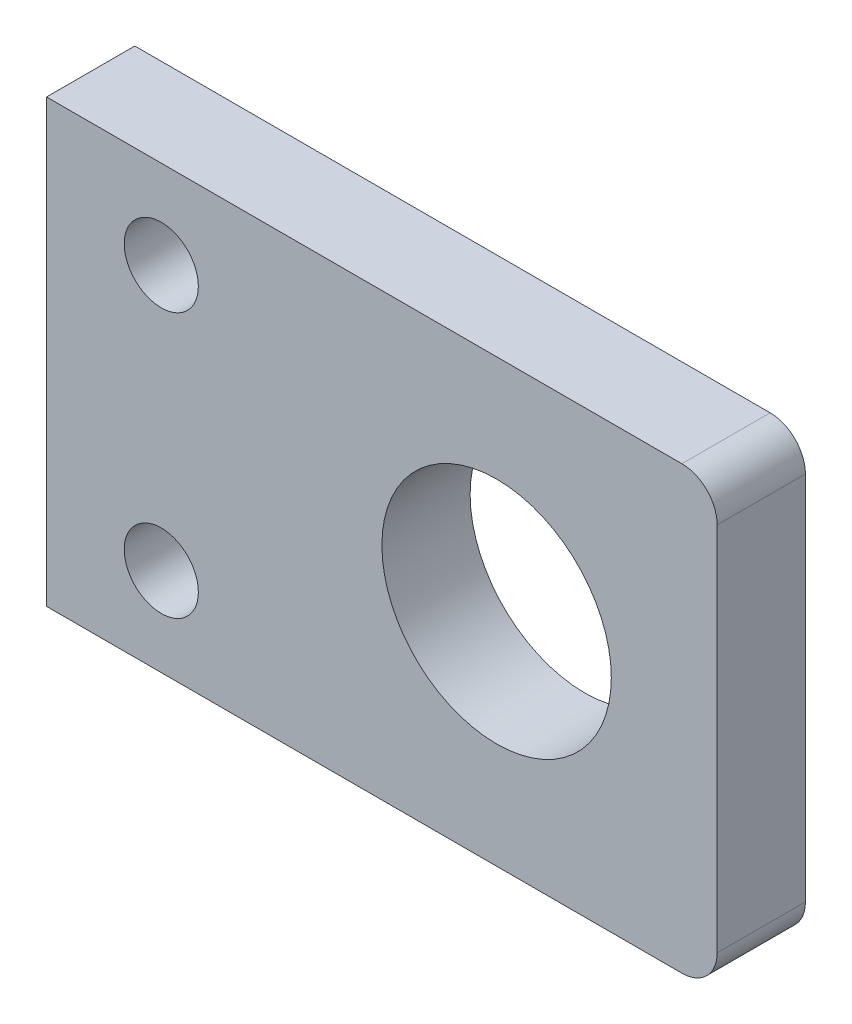
from build123d import *

# Parameters (mm, degrees)
SKETCH_1_R      = 2.1
SKETCH_1_R_2    = 6.5
EXTRUDE_1_DEPTH = 5


with BuildPart() as part:
    # 草图1 → 凸台-拉伸1 (new body)
    with BuildSketch(Plane.XY):
        with BuildLine():
            Line((-16.515544041, 16.418393782), (19.484455959, 16.418393782))
            ThreePointArc((19.484455959, 16.418393782), (20.898669521, 15.832607345), (21.484455959, 14.418393782))
            Line((21.484455959, 14.418393782), (21.484455959, -6.581606218))
            ThreePointArc((21.484455959, -6.581606218), (20.898669521, -7.99581978), (19.484455959, -8.581606218))
            Line((19.484455959, -8.581606218), (-16.515544041, -8.581606218))
            Line((-16.515544041, -8.581606218), (-16.515544041, 16.418393782))
        make_face()
        with Locations((-10.015544041, -3.581606218)):
            Circle(SKETCH_1_R, mode=Mode.SUBTRACT)
        with Locations((-10.015544041, 11.418393782)):
            Circle(SKETCH_1_R, mode=Mode.SUBTRACT)
        with Locations((8.984455959, 3.918393782)):
            Circle(SKETCH_1_R_2, mode=Mode.SUBTRACT)
    extrude(amount=EXTRUDE_1_DEPTH)


solid = part.part
